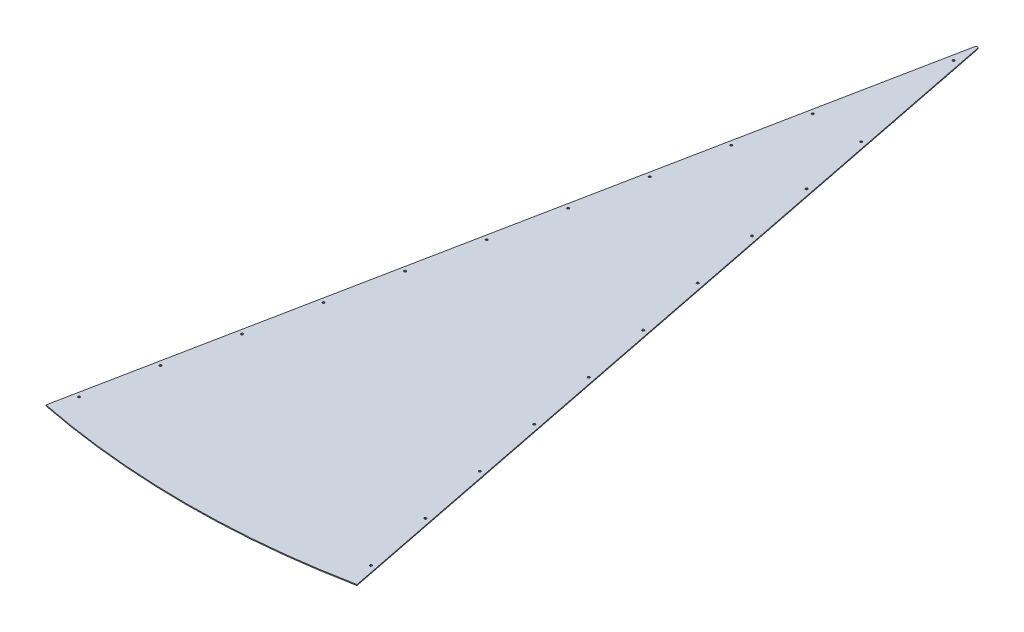
from build123d import *

# Parameters (mm, degrees)
BOSS_EXTRUDE1_DEPTH = 2.5
SKETCH2_R           = 3
CUT_EXTRUDE1_DEPTH  = 2.5


with BuildPart() as part:
    # Sketch1 → Boss-Extrude1 (new body)
    with BuildSketch(Plane(origin=(0, 0, 0), x_dir=(1, 0, 0), z_dir=(0, 1, 0))):
        with BuildLine():
            Line((-3.769046254, -18.94827508), (-419.444192335, -2108.688352867))
            ThreePointArc((-419.444192335, -2108.688352867), (0, -2150), (419.444192335, -2108.688352867))
            Line((419.444192335, -2108.688352867), (3.769046254, -18.94827508))
            ThreePointArc((3.769046254, -18.94827508), (0, -16.086966015), (-3.769046254, -18.94827508))
        make_face()
    extrude(amount=BOSS_EXTRUDE1_DEPTH)

    # Sketch2 → Cut-Extrude1 (cut)
    with BuildSketch(Plane(origin=(0, 2.5, 0), x_dir=(1, 0, 0), z_dir=(0, 1, 0))):
        with Locations((-393.622932114, -2045.511913266)):
            Circle(SKETCH2_R)
        with Locations((-357.141041897, -1862.105065831)):
            Circle(SKETCH2_R)
        with Locations((-320.65915168, -1678.698218395)):
            Circle(SKETCH2_R)
        with Locations((-284.177261463, -1495.29137096)):
            Circle(SKETCH2_R)
        with Locations((-247.695371246, -1311.884523525)):
            Circle(SKETCH2_R)
        with Locations((-211.213481029, -1128.477676089)):
            Circle(SKETCH2_R)
        with Locations((-174.731590812, -945.070828654)):
            Circle(SKETCH2_R)
        with Locations((-138.249700595, -761.663981218)):
            Circle(SKETCH2_R)
        with Locations((-101.767810378, -578.257133783)):
            Circle(SKETCH2_R)
        with Locations((-65.285920161, -394.850286348)):
            Circle(SKETCH2_R)
        with Locations((65.285920161, -394.850286348)):
            Circle(SKETCH2_R)
        with Locations((101.767810378, -578.257133783)):
            Circle(SKETCH2_R)
        with Locations((138.249700595, -761.663981218)):
            Circle(SKETCH2_R)
        with Locations((174.731590812, -945.070828654)):
            Circle(SKETCH2_R)
        with Locations((211.213481029, -1128.477676089)):
            Circle(SKETCH2_R)
        with Locations((247.695371246, -1311.884523525)):
            Circle(SKETCH2_R)
        with Locations((284.177261463, -1495.29137096)):
            Circle(SKETCH2_R)
        with Locations((320.65915168, -1678.698218395)):
            Circle(SKETCH2_R)
        with Locations((357.141041897, -1862.105065831)):
            Circle(SKETCH2_R)
        with Locations((393.622932114, -2045.511913266)):
            Circle(SKETCH2_R)
        with Locations((0, -80)):
            Circle(SKETCH2_R)
    extrude(amount=-CUT_EXTRUDE1_DEPTH, mode=Mode.SUBTRACT)


solid = part.part
